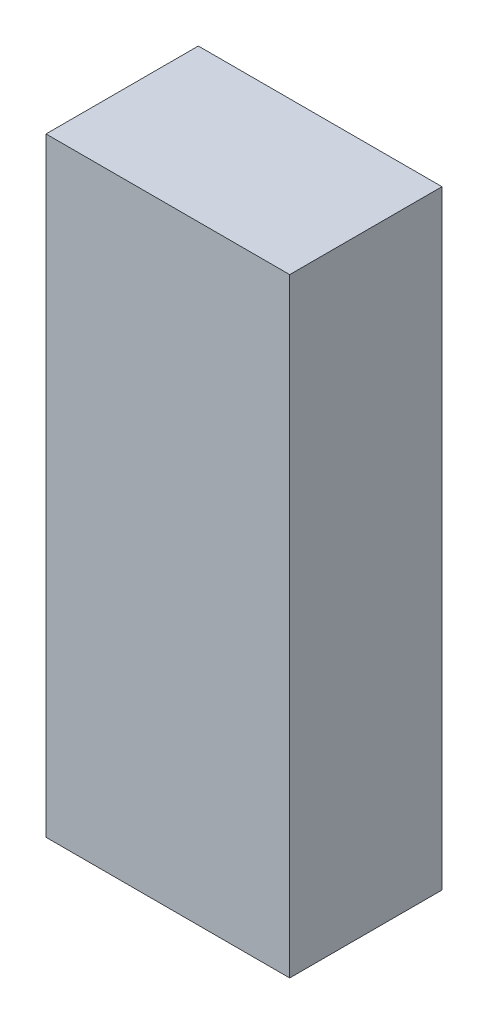
from build123d import *

# Parameters (mm, degrees)
SKETCH1_W           = 7.62
SKETCH1_H           = 19.05
BOSS_EXTRUDE1_DEPTH = 4.7625


with BuildPart() as part:
    # Sketch1 → Boss-Extrude1 (new body)
    with BuildSketch(Plane.XY):
        with Locations((3.81, 9.525)):
            Rectangle(SKETCH1_W, SKETCH1_H)
    extrude(amount=BOSS_EXTRUDE1_DEPTH)


solid = part.part
